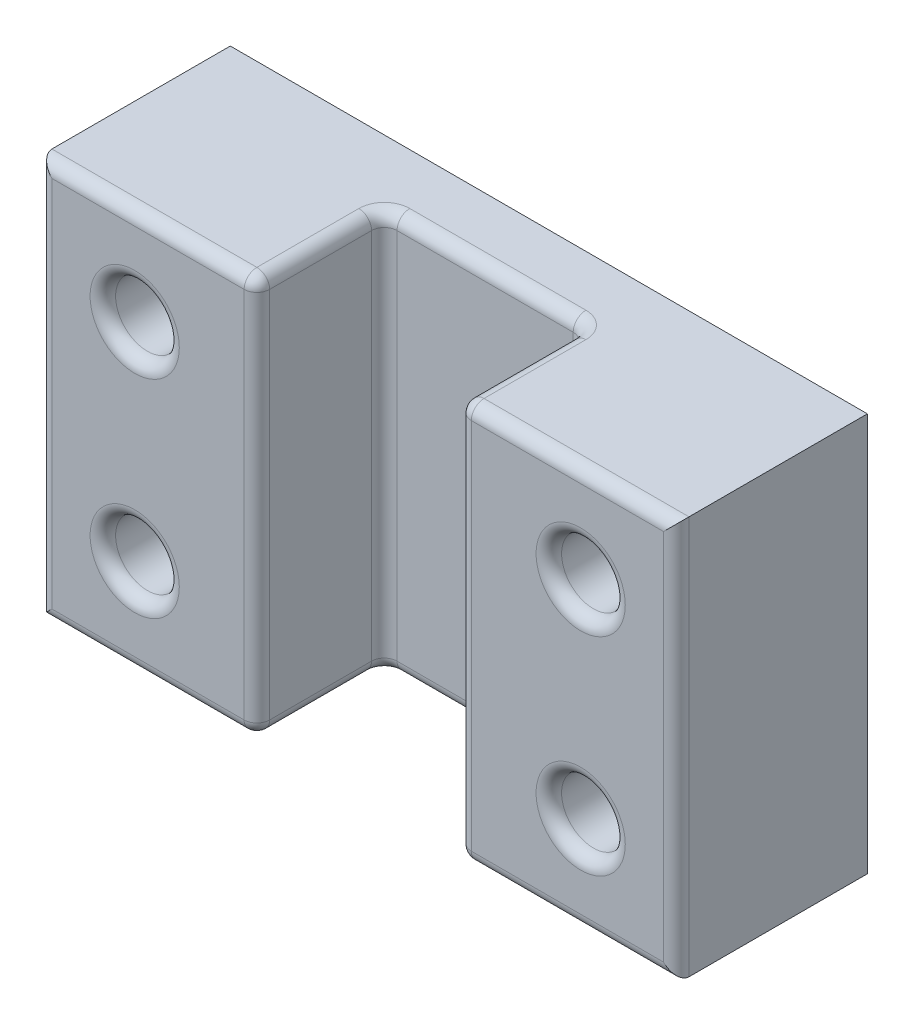
from build123d import *

# Parameters (mm, degrees)
SKETCH1_W           = 127
SKETCH1_H           = 79.410199556
SKETCH1_R           = 6.35
BOSS_EXTRUDE1_DEPTH = 38.1
SKETCH3_W           = 40.194306858
SKETCH3_H           = 79.410199556
CUT_EXTRUDE1_DEPTH  = 25.4
FILLET1_R           = 2.54
FILLET2_R           = 2.54


with BuildPart() as part:
    # Sketch1 → Boss-Extrude1 (new body)
    with BuildSketch(Plane.XY):
        Rectangle(SKETCH1_W, SKETCH1_H)
        with Locations((-44.45, 20.655099778)):
            Circle(SKETCH1_R, mode=Mode.SUBTRACT)
        with Locations((44.45, 20.655099778)):
            Circle(SKETCH1_R, mode=Mode.SUBTRACT)
        with Locations((44.45, -20.655099778)):
            Circle(SKETCH1_R, mode=Mode.SUBTRACT)
        with Locations((-44.45, -20.655099778)):
            Circle(SKETCH1_R, mode=Mode.SUBTRACT)
    extrude(amount=BOSS_EXTRUDE1_DEPTH)

    # Sketch3 → Cut-Extrude1 (cut)
    with BuildSketch(Plane.XY.offset(38.1)):
        Rectangle(SKETCH3_W, SKETCH3_H)
    extrude(amount=-CUT_EXTRUDE1_DEPTH, mode=Mode.SUBTRACT)

    # Fillet1
    fillet1_edges = [part.edges().sort_by_distance(p)[0] for p in [
        (-63.5, 0, 38.1),
        (38.1, 20.655099778, 38.1),
        (-41.798576715, -39.705099778, 38.1),
        (38.1, -20.655099778, 38.1),
        (41.798576715, -39.705099778, 38.1),
        (-41.798576715, 39.705099778, 38.1),
        (20.097153429, 0, 12.7),
        (20.097153429, 39.705099778, 25.4),
        (0, -39.705099778, 12.7),
        (20.097153429, -39.705099778, 25.4),
        (-20.097153429, 0, 12.7),
        (-20.097153429, -39.705099778, 25.4),
        (0, 39.705099778, 12.7),
        (-20.097153429, 39.705099778, 25.4),
        (20.097153429, 0, 38.1),
        (-20.097153429, 0, 38.1),
        (63.5, 0, 38.1),
        (41.798576715, 39.705099778, 38.1),
    ]]
    fillet(fillet1_edges, radius=FILLET1_R)

    # Fillet2
    fillet2_edges = [part.edges().sort_by_distance(p)[0] for p in [
        (-50.8, 20.655099778, 38.1),
        (-50.8, -20.655099778, 38.1),
    ]]
    fillet(fillet2_edges, radius=FILLET2_R)


solid = part.part
